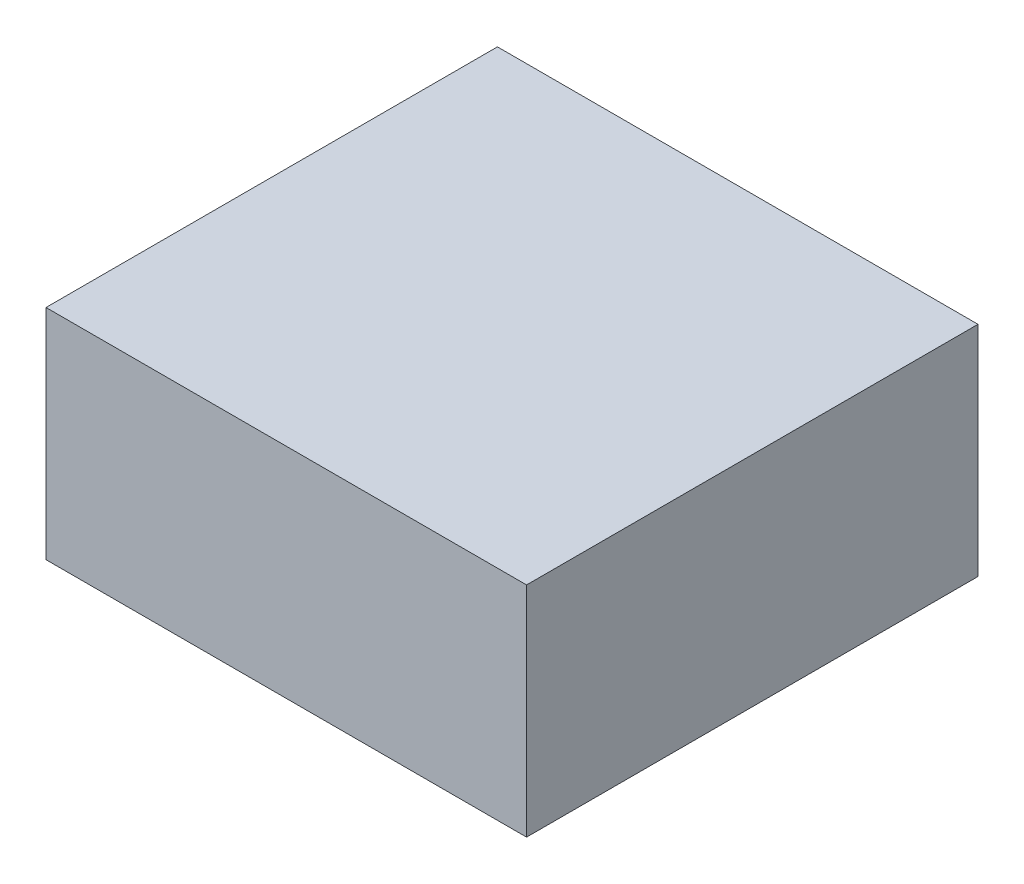
from build123d import *

# Parameters (mm, degrees)
ESQUISSE1_W        = 66
ESQUISSE1_H        = 62
BOSS_EXTRU_1_DEPTH = 30


with BuildPart() as part:
    # Esquisse1 → Boss.-Extru.1 (new body)
    with BuildSketch(Plane(origin=(0, 0, 0), x_dir=(1, 0, 0), z_dir=(0, 1, 0))):
        Rectangle(ESQUISSE1_W, ESQUISSE1_H)
    extrude(amount=BOSS_EXTRU_1_DEPTH)


solid = part.part
